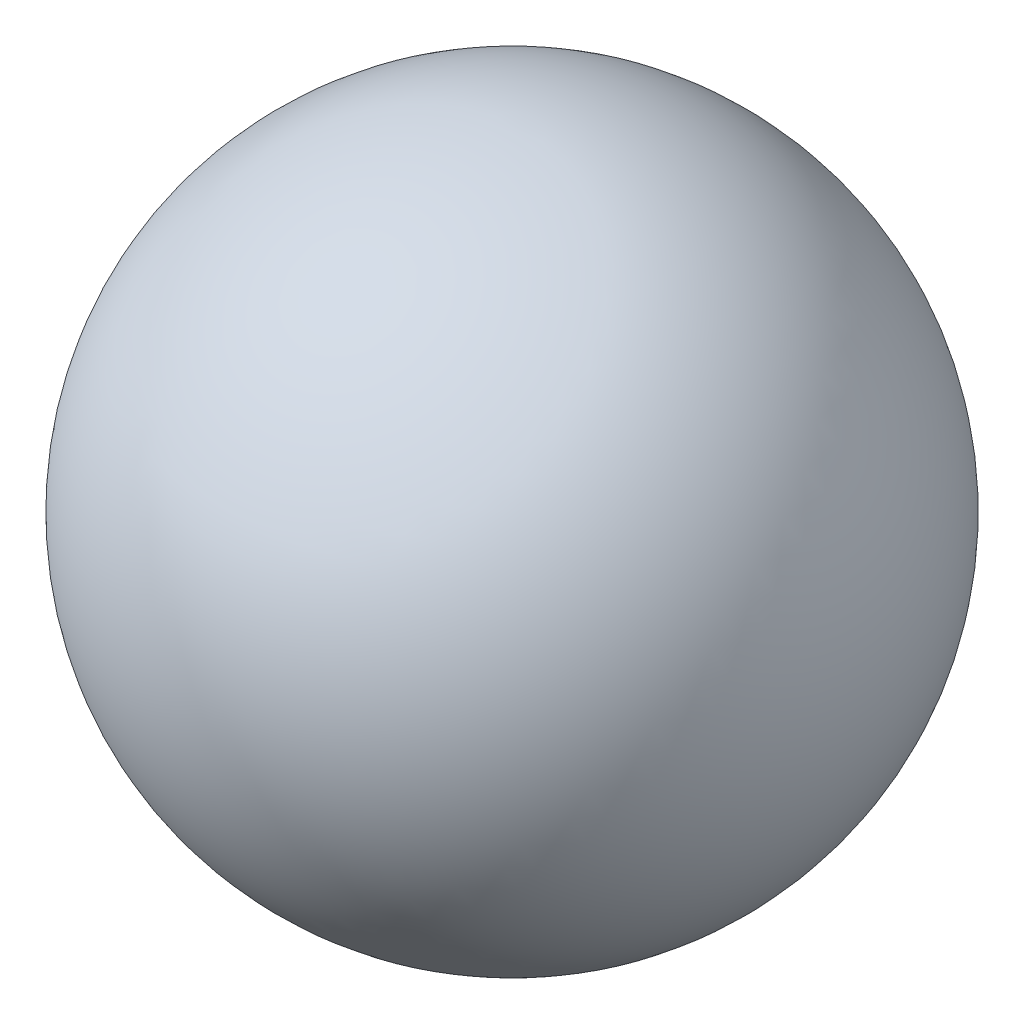
from build123d import *


with BuildPart() as part:
    # Croquis1 → Revolución1 (revolve)
    with BuildSketch(Plane.XY):
        with BuildLine():
            Line((0, 6.75), (0, -6.75))
            ThreePointArc((0, -6.75), (6.75, 0), (0, 6.75))
        make_face()
    revolve(axis=Axis((0, 6.75, 0), (0, -1, 0)))


solid = part.part
